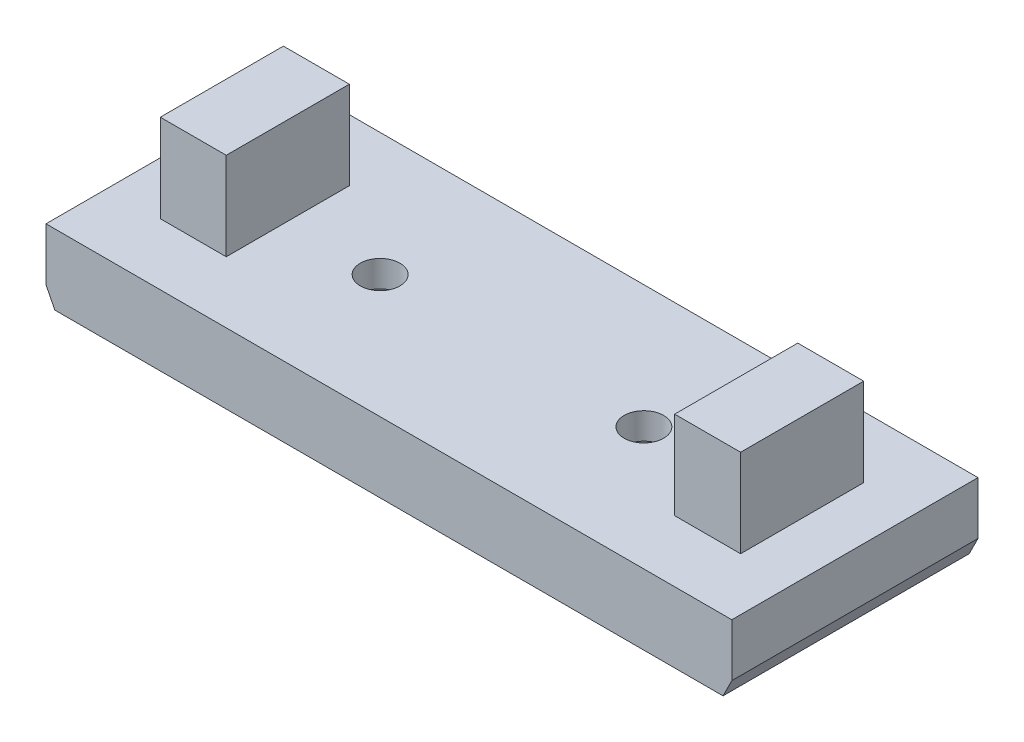
from build123d import *

# Parameters (mm, degrees)
SKETCH_1_W          = 39
SKETCH_1_H          = 14
EXTRUDE_1_DEPTH     = 4
CUT_EXTRUDE_1_DEPTH = 2.5
SKETCH_3_R          = 1.125
CUT_EXTRUDE_2_DEPTH = 4
SKETCH_4_W          = 3.75
SKETCH_4_H          = 7
EXTRUDE_2_DEPTH     = 5
CUT_EXTRUDE_4_DEPTH = 14


with BuildPart() as part:
    # 스케치1 → 보스-돌출1 (new body)
    with BuildSketch(Plane(origin=(0, 0, 0), x_dir=(1, 0, 0), z_dir=(0, 1, 0))):
        Rectangle(SKETCH_1_W, SKETCH_1_H)
    extrude(amount=EXTRUDE_1_DEPTH)

    # 스케치2 → 컷-돌출1 (cut)
    with BuildSketch(Plane.XZ):
        Polygon((10.011473671, 0), (8.755736835, 2.175), (6.244263165, 2.175), (4.988526329, 0), (6.244263165, -2.175), (8.755736835, -2.175), align=None)
        Polygon((-4.988526329, 0), (-6.244263165, 2.175), (-8.755736835, 2.175), (-10.011473671, 0), (-8.755736835, -2.175), (-6.244263165, -2.175), align=None)
    extrude(amount=-CUT_EXTRUDE_1_DEPTH, mode=Mode.SUBTRACT)

    # 스케치3 → 컷-돌출2 (cut)
    with BuildSketch(Plane.XZ):
        with Locations((-7.5, 0)):
            Circle(SKETCH_3_R)
        with Locations((7.5, 0)):
            Circle(SKETCH_3_R)
    extrude(amount=-CUT_EXTRUDE_2_DEPTH, mode=Mode.SUBTRACT)

    # 스케치4 → 보스-돌출2 (add)
    with BuildSketch(Plane(origin=(0, 4, 0), x_dir=(1, 0, 0), z_dir=(0, 1, 0))):
        with Locations((-14.625, 0)):
            Rectangle(SKETCH_4_W, SKETCH_4_H)
        with Locations((14.625, 0)):
            Rectangle(SKETCH_4_W, SKETCH_4_H)
    extrude(amount=EXTRUDE_2_DEPTH)

    # 스케치5 → 컷-돌출4 (cut)
    with BuildSketch(Plane.XY.offset(7)):
        Polygon((-19.5, 1), (-19, 0), (-19.5, 0), align=None)
        Polygon((19.5, 1), (19.5, 0), (19, 0), align=None)
    extrude(amount=-CUT_EXTRUDE_4_DEPTH, mode=Mode.SUBTRACT)


solid = part.part
